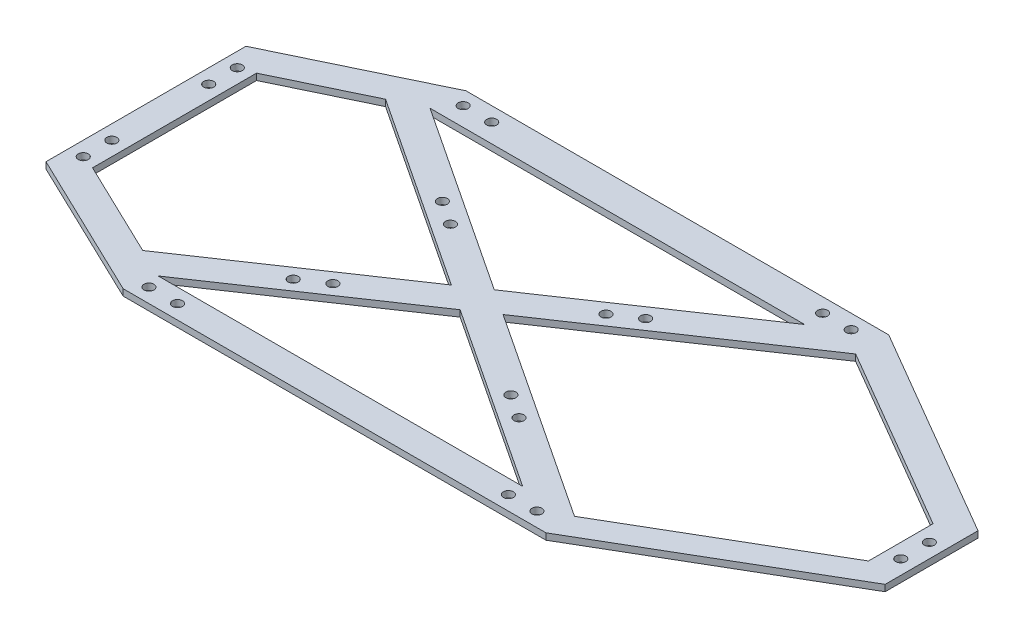
from build123d import *

# Parameters (mm, degrees)
BOSS_EXTRUDE3_DEPTH = 4.5
SKETCH2_R           = 3.5
CUT_EXTRUDE2_DEPTH  = 4.5
SKETCH3_R           = 3.5
CUT_EXTRUDE3_DEPTH  = 4.5
SKETCH4_R           = 3.5
CUT_EXTRUDE4_DEPTH  = 4.5
SKETCH5_R           = 3.5
CUT_EXTRUDE5_DEPTH  = 4.5
SKETCH6_R           = 3.5
CUT_EXTRUDE6_DEPTH  = 4.5
SKETCH7_R           = 3.5
CUT_EXTRUDE7_DEPTH  = 4.5
SKETCH8_R           = 3.5
CUT_EXTRUDE8_DEPTH  = 4.5
SKETCH9_R           = 3.5
CUT_EXTRUDE9_DEPTH  = 4.5


with BuildPart() as part:
    # Sketch1 → Boss-Extrude3 (new body)
    with BuildSketch(Plane(origin=(0, 0, 0), x_dir=(1, 0, 0), z_dir=(0, 1, 0))):
        Polygon((-183.349573846, -2.857581752), (-179.118755434, 0), (-187.675629618, 0), align=None)
        Polygon((-179.118755434, 0), (-151.388696713, 0), (-165.408042798, 9.260497243), align=None)
        Polygon((-165.284400003, -14.790555769), (-147.342868955, -2.672476774), (-151.388696713, 0), (-179.118755434, 0), (-183.349573846, -2.857581752), align=None)
        Polygon((-147.342868955, -2.672476774), (-143.386109387, 0), (-151.388696713, 0), align=None)
        Polygon((-143.386109387, 0), (0, 96.845926684), (-35.732646047, 96.845926684), (-165.408042798, 9.260497243), (-151.388696713, 0), align=None)
        Polygon((-36.286932906, -100), (0, -100), (-147.342868955, -2.672476774), (-165.284400003, -14.790555769), align=None)
        Polygon((-165.408042798, 9.260497243), (-298.002482939, 96.845926684), (-319.003928208, 86.749077997), (-187.675629618, 0), (-179.118755434, 0), align=None)
        Polygon((-312.316233719, -89.964315732), (-291.442010442, -100), (-165.284400003, -14.790555769), (-183.349573846, -2.857581752), align=None)
        Polygon((0, -120), (0, -100), (-36.286932906, -100), (-291.442010442, -100), (-312.316233719, -89.964315732), (-380, -57.424043482), (-380, 0), (-400, 0), (-400, -70), (-296, -120), align=None)
        Polygon((130, -24.166666667), (0, -100), (0, -120), (150, -32.5), (150, 0), (130, 0), align=None)
        Polygon((0, 120), (0, 96.845926684), (130, 21.012593351), (130, 0), (150, 0), (150, 32.5), align=None)
        Polygon((-35.732646047, 96.845926684), (0, 96.845926684), (0, 120), (-296, 120), (-400, 70), (-400, 0), (-380, 0), (-380, 57.424043482), (-319.003928208, 86.749077997), (-298.002482939, 96.845926684), align=None)
    extrude(amount=BOSS_EXTRUDE3_DEPTH)

    # Sketch2 → Cut-Extrude2 (cut)
    with BuildSketch(Plane(origin=(0, 4.5, 0), x_dir=(1, 0, 0), z_dir=(0, 1, 0))):
        with Locations((-16.286932906, -110)):
            Circle(SKETCH2_R)
        with Locations((-36.286932906, -110)):
            Circle(SKETCH2_R)
    cut_extrude2 = extrude(amount=-CUT_EXTRUDE2_DEPTH, mode=Mode.SUBTRACT)

    # Mirror1: Cut-Extrude2 across plane
    add(cut_extrude2.mirror(Plane.XY), mode=Mode.SUBTRACT)

    # Sketch3 → Cut-Extrude3 (cut)
    with BuildSketch(Plane(origin=(0, 4.5, 0), x_dir=(1, 0, 0), z_dir=(0, 1, 0))):
        with Locations((-287.942010442, -110)):
            Circle(SKETCH3_R)
        with Locations((-267.942010442, -110)):
            Circle(SKETCH3_R)
    cut_extrude3 = extrude(amount=-CUT_EXTRUDE3_DEPTH, mode=Mode.SUBTRACT)

    # Mirror2: Cut-Extrude3 across plane
    add(cut_extrude3.mirror(Plane.XY), mode=Mode.SUBTRACT)

    # Sketch4 → Cut-Extrude4 (cut)
    with BuildSketch(Plane(origin=(0, 4.5, 0), x_dir=(1, 0, 0), z_dir=(0, 1, 0))):
        with Locations((140, 8.422963342)):
            Circle(SKETCH4_R)
        with Locations((140, -11.577036658)):
            Circle(SKETCH4_R)
    extrude(amount=-CUT_EXTRUDE4_DEPTH, mode=Mode.SUBTRACT)

    # Sketch5 → Cut-Extrude5 (cut)
    with BuildSketch(Plane(origin=(0, 4.5, 0), x_dir=(1, 0, 0), z_dir=(0, 1, 0))):
        with Locations((-390, 53.924043482)):
            Circle(SKETCH5_R)
        with Locations((-390, 33.924043482)):
            Circle(SKETCH5_R)
    cut_extrude5 = extrude(amount=-CUT_EXTRUDE5_DEPTH, mode=Mode.SUBTRACT)

    # Mirror3: Cut-Extrude5 across plane
    add(cut_extrude5.mirror(Plane.XY), mode=Mode.SUBTRACT)

    # Sketch6 → Cut-Extrude6 (cut)
    with BuildSketch(Plane(origin=(0, 4.5, 0), x_dir=(1, 0, 0), z_dir=(0, 1, 0))):
        with Locations((-237.21688879, 44.709233314)):
            Circle(SKETCH6_R)
        with Locations((-220.528931491, 33.685981472)):
            Circle(SKETCH6_R)
    extrude(amount=-CUT_EXTRUDE6_DEPTH, mode=Mode.SUBTRACT)

    # Sketch7 → Cut-Extrude7 (cut)
    with BuildSketch(Plane(origin=(0, 4.5, 0), x_dir=(1, 0, 0), z_dir=(0, 1, 0))):
        with Locations((-242.235781203, -54.69781901)):
            Circle(SKETCH7_R)
        with Locations((-225.662040668, -43.503573852)):
            Circle(SKETCH7_R)
    extrude(amount=-CUT_EXTRUDE7_DEPTH, mode=Mode.SUBTRACT)

    # Sketch8 → Cut-Extrude8 (cut)
    with BuildSketch(Plane(origin=(0, 4.5, 0), x_dir=(1, 0, 0), z_dir=(0, 1, 0))):
        with Locations((-94.973221843, 44.766341696)):
            Circle(SKETCH8_R)
        with Locations((-111.546962379, 33.572096538)):
            Circle(SKETCH8_R)
    extrude(amount=-CUT_EXTRUDE8_DEPTH, mode=Mode.SUBTRACT)

    # Sketch9 → Cut-Extrude9 (cut)
    with BuildSketch(Plane(origin=(0, 4.5, 0), x_dir=(1, 0, 0), z_dir=(0, 1, 0))):
        with Locations((-95.871017698, -48.656965194)):
            Circle(SKETCH9_R)
        with Locations((-79.183060399, -59.680217036)):
            Circle(SKETCH9_R)
    extrude(amount=-CUT_EXTRUDE9_DEPTH, mode=Mode.SUBTRACT)


solid = part.part
